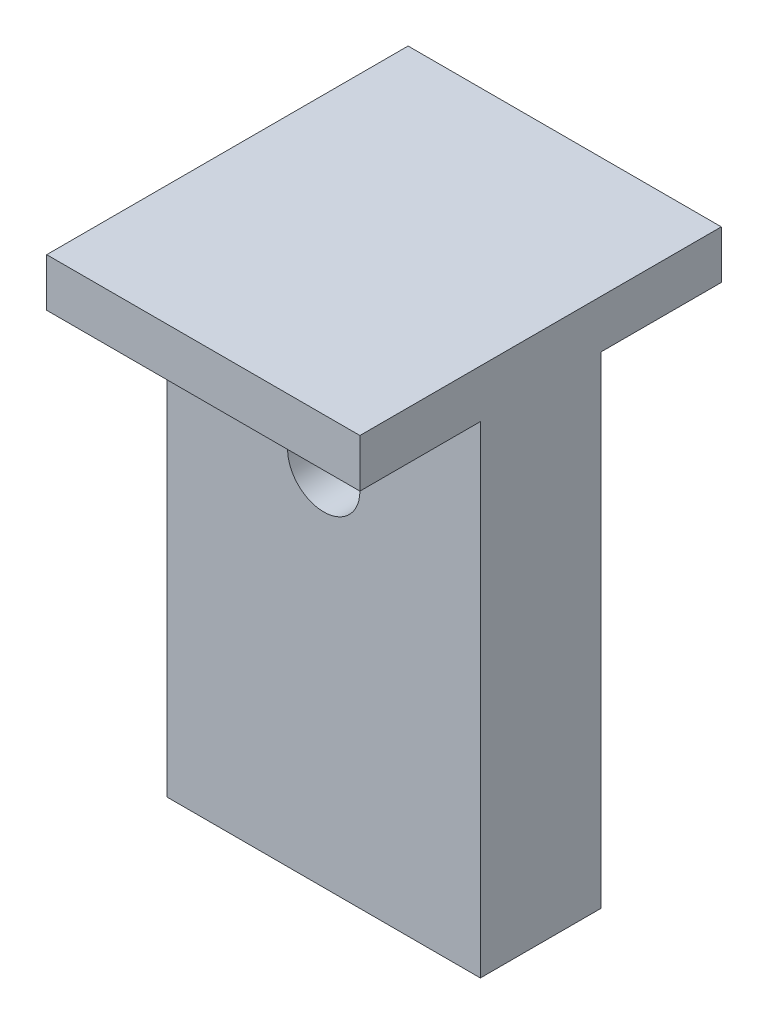
from build123d import *

# Parameters (mm, degrees)
SKETCH1_W                = 13
SKETCH1_H                = 5
BOSS_EXTRUDE1_DEPTH      = 20
M2_TAPPED_HOLE1_D        = 1.6
M2_TAPPED_HOLE1_DEPTH    = 5.2
M2_TAPPED_HOLE1_TIP      = 0.480688495
F_3_0_3_DIAMETER_HOLE1_D = 3
SKETCH7_W                = 13
SKETCH7_H                = 15
BOSS_EXTRUDE2_DEPTH      = 2


with BuildPart() as part:
    # Sketch1 → Boss-Extrude1 (new body)
    with BuildSketch(Plane(origin=(0, 0, 0), x_dir=(1, 0, 0), z_dir=(0, 1, 0))):
        Rectangle(SKETCH1_W, SKETCH1_H)
    extrude(amount=BOSS_EXTRUDE1_DEPTH)

    # M2 Tapped Hole1
    with Locations(Plane(origin=(0, 0, 0), x_dir=(0, 0, -1), z_dir=(0, -1, 0))):
        with Locations((0, 0)):
            Hole(M2_TAPPED_HOLE1_D / 2, depth=M2_TAPPED_HOLE1_DEPTH)
            with Locations((0, 0, -(M2_TAPPED_HOLE1_DEPTH + M2_TAPPED_HOLE1_TIP / 2))):  # 118° drill point
                Cone(0, M2_TAPPED_HOLE1_D / 2, M2_TAPPED_HOLE1_TIP, mode=Mode.SUBTRACT)

    # Sketch4 → Ø1.0mm Dowel Hole1 (revolve, cut)
    with BuildSketch(Plane(origin=(-5, 0, 0), x_dir=(0, 0, -1), z_dir=(1, 0, 0))):
        Polygon((0, 0), (0, 4.30043031), (0.5, 4), (0.5, 0), align=None)
    f_1_0mm_dowel_hole1 = revolve(axis=Axis((-5, -6.35, 0), (0, 1, 0)), mode=Mode.SUBTRACT)

    # Mirror1: Ø1.0mm Dowel Hole1 across plane
    add(f_1_0mm_dowel_hole1.mirror(Plane(origin=(0, 0, 0), x_dir=(0, 0, 1), z_dir=(1, 0, 0))), mode=Mode.SUBTRACT)

    # Ø3.0 (3) Diameter Hole1 (through all)
    with Locations(Plane(origin=(0, 15, 2.5), x_dir=(1, 0, 0), z_dir=(0, 0, 1))):
        with Locations((0, 0)):
            Hole(F_3_0_3_DIAMETER_HOLE1_D / 2)

    # Sketch7 → Boss-Extrude2 (add)
    with BuildSketch(Plane(origin=(0, 20, 0), x_dir=(1, 0, 0), z_dir=(0, 1, 0))):
        Rectangle(SKETCH7_W, SKETCH7_H)
    extrude(amount=BOSS_EXTRUDE2_DEPTH)


solid = part.part
